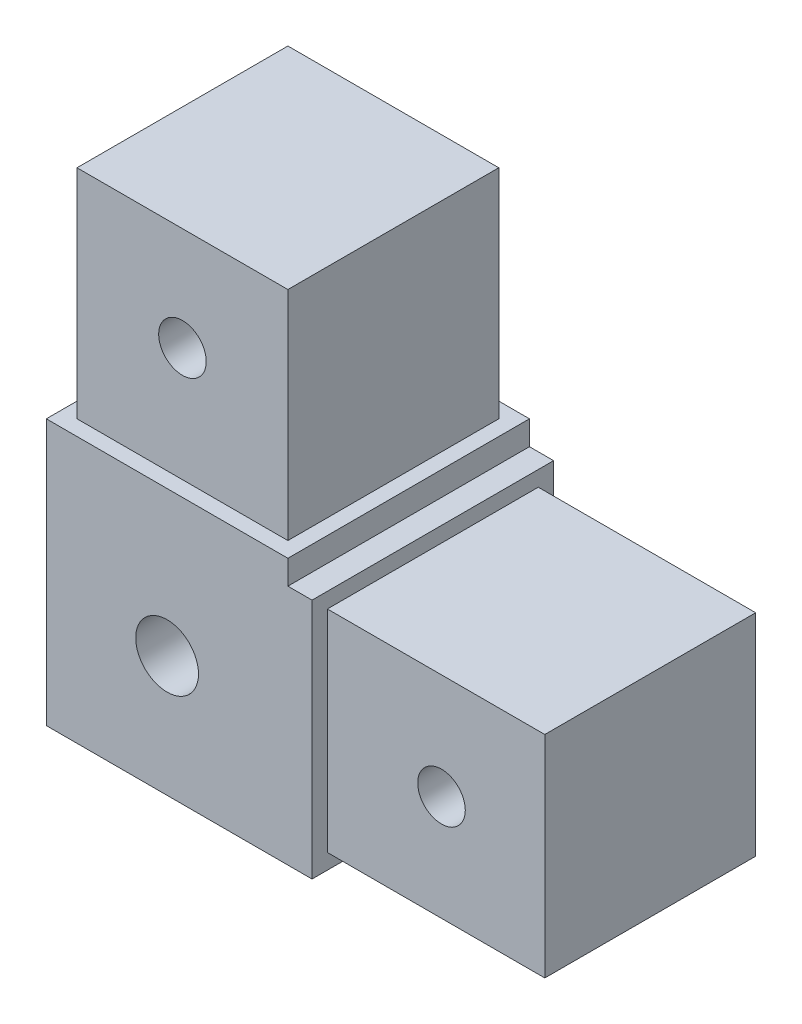
from build123d import *

# Parameters (mm, degrees)
SKETCH1_W                   = 50.8
SKETCH1_H                   = 50.8
BOSS_EXTRUDE1_DEPTH         = 12.7
SKETCH2_W                   = 25.4
SKETCH2_H                   = 25.4
CUT_EXTRUDE1_DEPTH          = 26.4
SKETCH3_W                   = 25.4
SKETCH3_H                   = 25.4
SKETCH3_W_2                 = 22.1742
SKETCH3_H_2                 = 22.1742
CUT_EXTRUDE2_DEPTH          = 22.86
SKETCH5_W                   = 25.4
SKETCH5_H                   = 25.4
SKETCH5_W_2                 = 22.1742
SKETCH5_H_2                 = 22.1742
CUT_EXTRUDE4_DEPTH          = 22.86
SKETCH7_R                   = 3.3
CUT_EXTRUDE6_DEPTH          = 26.4
TAP_DRILL_FOR_M6X1_0_TAP1_D = 5


with BuildPart() as part:
    # Sketch1 → Boss-Extrude1 (new body, symmetric)
    with BuildSketch(Plane.XY):
        Rectangle(SKETCH1_W, SKETCH1_H)
    extrude(amount=BOSS_EXTRUDE1_DEPTH, both=True)

    # Sketch2 → Cut-Extrude1 (cut, through all)
    with BuildSketch(Plane.XY.offset(12.7)):
        with Locations((12.7, 12.7)):
            Rectangle(SKETCH2_W, SKETCH2_H)
    extrude(amount=-CUT_EXTRUDE1_DEPTH, mode=Mode.SUBTRACT)

    # Sketch3 → Cut-Extrude2 (cut)
    with BuildSketch(Plane(origin=(25.4, 0, 0), x_dir=(0, 0, -1), z_dir=(1, 0, 0))):
        with Locations((0, -12.7)):
            Rectangle(SKETCH3_W, SKETCH3_H)
        with Locations((0, -12.7)):
            Rectangle(SKETCH3_W_2, SKETCH3_H_2, mode=Mode.SUBTRACT)
    extrude(amount=-CUT_EXTRUDE2_DEPTH, mode=Mode.SUBTRACT)

    # Sketch5 → Cut-Extrude4 (cut)
    with BuildSketch(Plane(origin=(0, 25.4, 0), x_dir=(1, 0, 0), z_dir=(0, 1, 0))):
        with Locations((-12.7, 0)):
            Rectangle(SKETCH5_W, SKETCH5_H)
        with Locations((-12.7, 0)):
            Rectangle(SKETCH5_W_2, SKETCH5_H_2, mode=Mode.SUBTRACT)
    extrude(amount=-CUT_EXTRUDE4_DEPTH, mode=Mode.SUBTRACT)

    # Sketch7 → Cut-Extrude6 (cut, through all)
    with BuildSketch(Plane.XY.offset(12.7)):
        with Locations((-12.7, -12.7)):
            Circle(SKETCH7_R)
    extrude(amount=-CUT_EXTRUDE6_DEPTH, mode=Mode.SUBTRACT)

    # Tap Drill for M6x1.0 Tap1 (through all)
    with Locations(Plane.XY.offset(11.0871)):
        with Locations((14.54, -12.6979), (-12.6979, 14.54)):
            Hole(TAP_DRILL_FOR_M6X1_0_TAP1_D / 2)


solid = part.part
